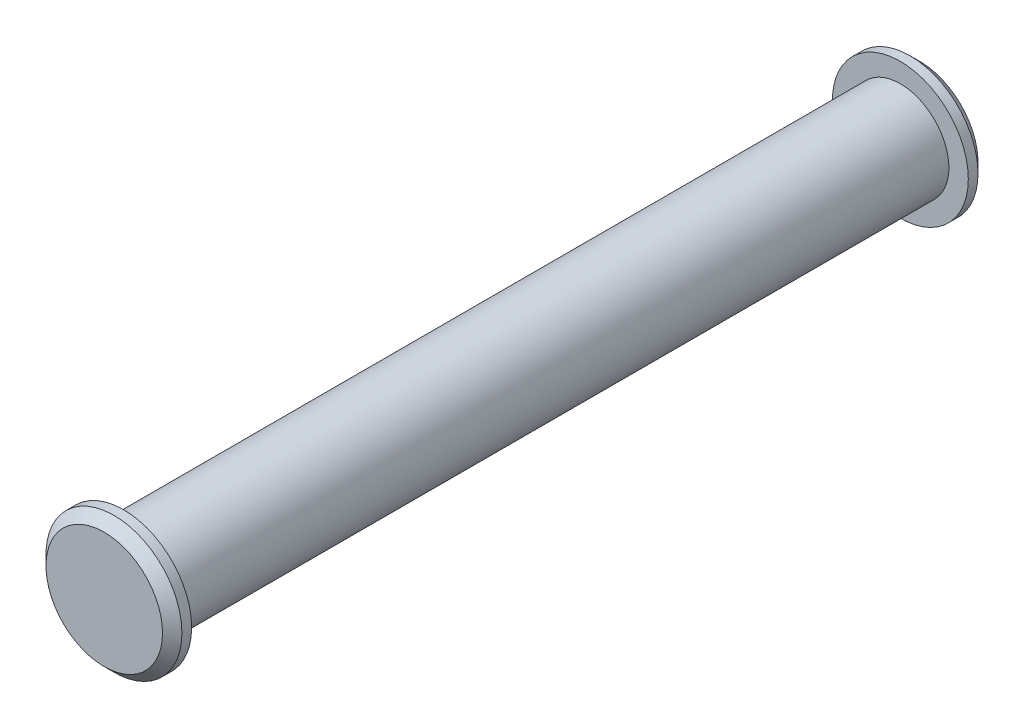
from build123d import *

# Parameters (mm, degrees)
SKETCH1_R           = 2.5
BOSS_EXTRUDE1_DEPTH = 20
SKETCH2_R           = 3.5
BOSS_EXTRUDE2_DEPTH = 1
CHAMFER1_SIZE       = 0.5


with BuildPart() as part:
    # Sketch1 → Boss-Extrude1 (new body, symmetric)
    with BuildSketch(Plane.XY):
        Circle(SKETCH1_R)
    extrude(amount=BOSS_EXTRUDE1_DEPTH, both=True)

    # Sketch2 → Boss-Extrude2 (add)
    with BuildSketch(Plane.XY.offset(20)):
        Circle(SKETCH2_R)
    boss_extrude2 = extrude(amount=BOSS_EXTRUDE2_DEPTH)

    # Mirror1: Boss-Extrude2 across plane
    add(boss_extrude2.mirror(Plane.XY))

    # Chamfer1
    chamfer1_edges = [part.edges().sort_by_distance(p)[0] for p in [
        (-3.5, 0, 21),
        (-3.5, 0, -21),
    ]]
    chamfer(chamfer1_edges, length=CHAMFER1_SIZE)


solid = part.part
